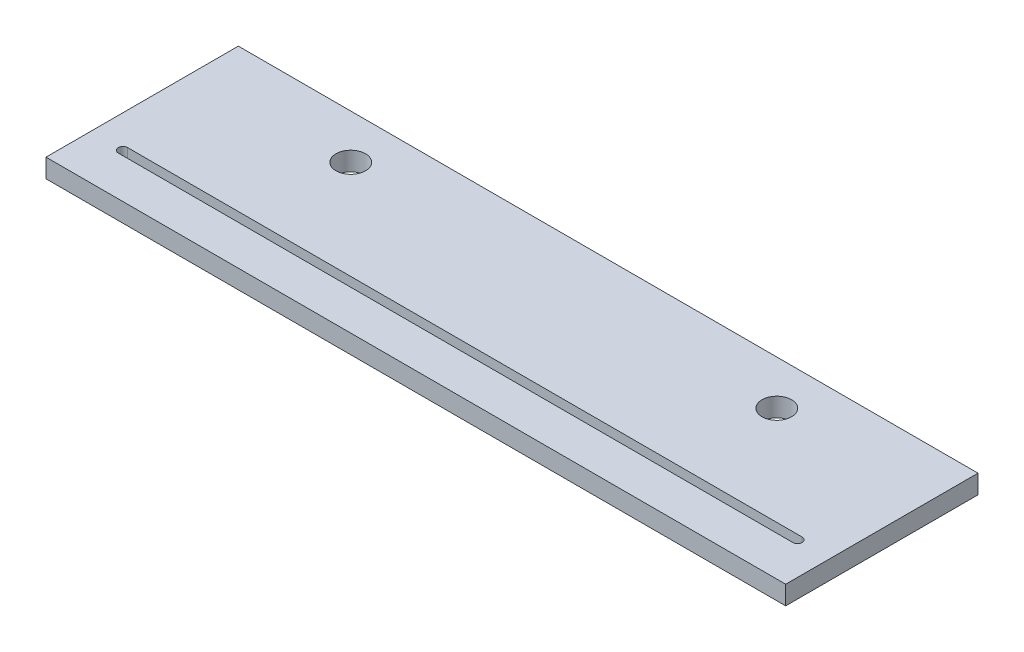
from build123d import *

# Parameters (mm, degrees)
SALIENTE_EXTRUIR1_DEPTH = 6.35
CROQUIS2_R              = 5
CORTAR_EXTRUIR3_DEPTH   = 7.35


with BuildPart() as part:
    # Croquis1 → Saliente-Extruir1 (new body)
    with BuildSketch(Plane(origin=(0, 0, 0), x_dir=(1, 0, 0), z_dir=(0, 1, 0))):
        Polygon((-125, -25), (-125, -40), (125, -40), (125, -25), (125, 25), (-125, 25), align=None)
    extrude(amount=SALIENTE_EXTRUIR1_DEPTH)

    # Croquis2 → Cortar-Extruir3 (cut, through all)
    with BuildSketch(Plane(origin=(0, 6.35, 0), x_dir=(1, 0, 0), z_dir=(0, 1, 0))):
        with Locations((-72, 10)):
            Circle(CROQUIS2_R)
        with Locations((72, 10)):
            Circle(CROQUIS2_R)
        with BuildLine():
            Line((114, -23.4125), (-114, -23.4125))
            ThreePointArc((-114, -23.4125), (-115.5875, -25), (-114, -26.5875))
            Line((-114, -26.5875), (114, -26.5875))
            ThreePointArc((114, -26.5875), (115.5875, -25), (114, -23.4125))
        make_face()
    extrude(amount=-CORTAR_EXTRUIR3_DEPTH, mode=Mode.SUBTRACT)


solid = part.part
